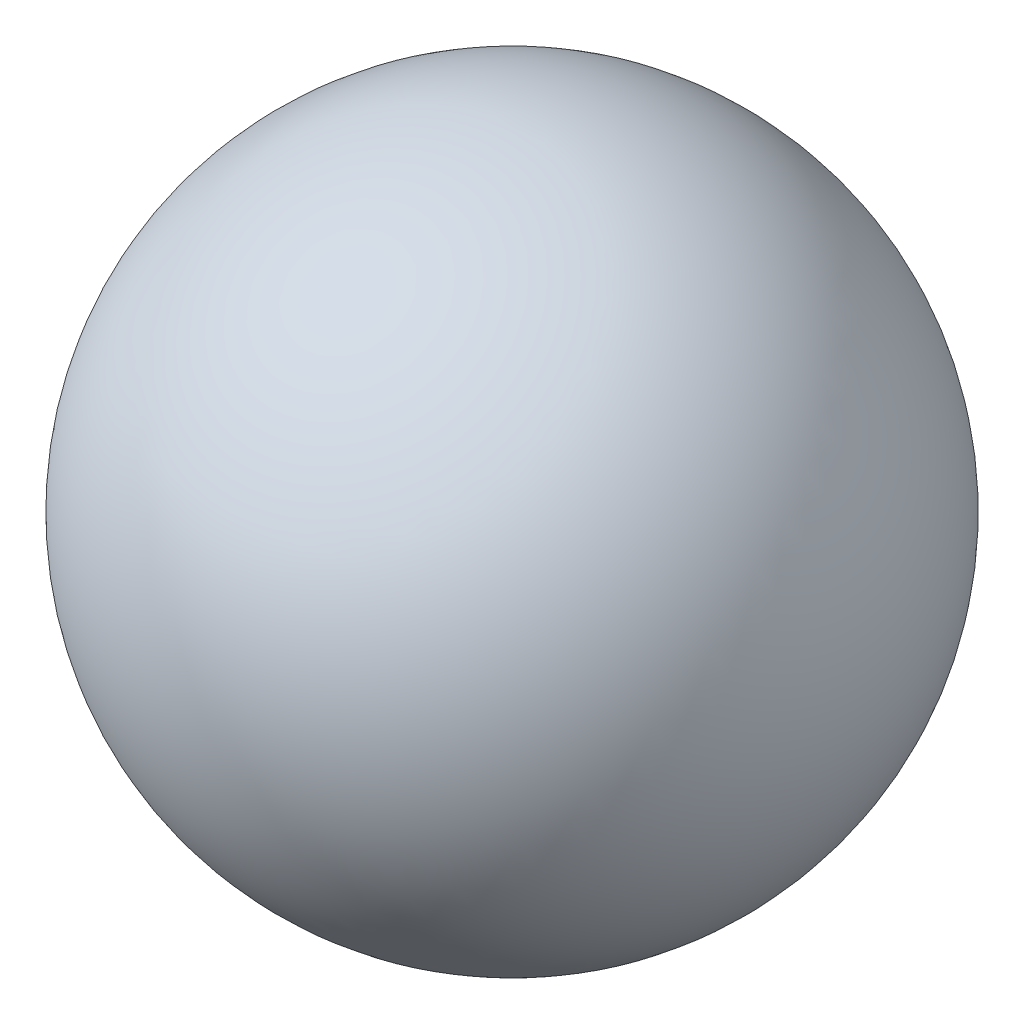
from build123d import *


with BuildPart() as part:
    # Sketch1 → Revolve1 (revolve)
    with BuildSketch(Plane.XY):
        with BuildLine():
            Line((16.592916275, 29.579011872), (16.592916275, -30.420988128))
            ThreePointArc((16.592916275, -30.420988128), (46.592916275, -0.420988128), (16.592916275, 29.579011872))
        make_face()
    revolve(axis=Axis((16.592916275, 29.579011872, 0), (0, -1, 0)))


solid = part.part
